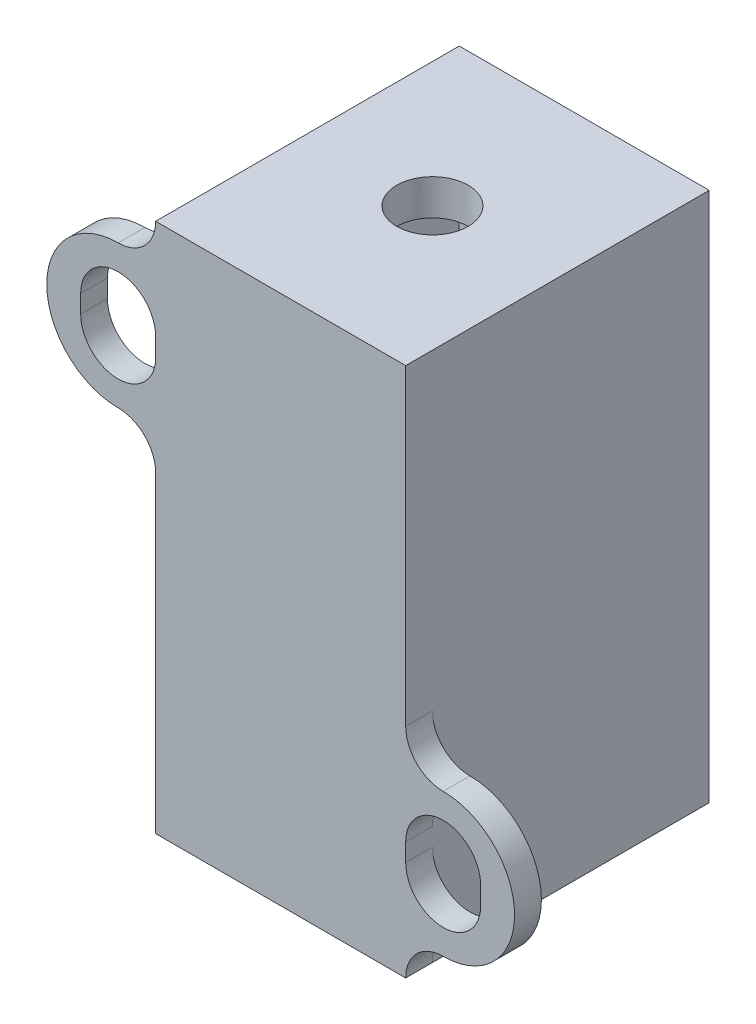
from build123d import *

# Parameters (mm, degrees)
SKETCH1_W           = 14
SKETCH1_H           = 29.7
BOSS_EXTRUDE1_DEPTH = 17
SKETCH2_R           = 2
CUT_EXTRUDE1_DEPTH  = 30.7
SKETCH3_R           = 4
CUT_EXTRUDE2_DEPTH  = 27.7
CUT_EXTRUDE4_START  = -2
SKETCH4_W           = 10
SKETCH4_H           = 13
CUT_EXTRUDE4_DEPTH  = 25.7
BOSS_EXTRUDE2_DEPTH = 1.5


with BuildPart() as part:
    # Sketch1 → Boss-Extrude1 (new body)
    with BuildSketch(Plane.XY):
        with Locations((7, 14.85)):
            Rectangle(SKETCH1_W, SKETCH1_H)
    extrude(amount=BOSS_EXTRUDE1_DEPTH)

    # Sketch2 → Cut-Extrude1 (cut, through all)
    with BuildSketch(Plane(origin=(0, 29.7, 0), x_dir=(1, 0, 0), z_dir=(0, 1, 0))):
        with Locations((7, -8.5)):
            Circle(SKETCH2_R)
    extrude(amount=-CUT_EXTRUDE1_DEPTH, mode=Mode.SUBTRACT)

    # Sketch3 → Cut-Extrude2 (cut)
    with BuildSketch(Plane.XZ):
        with Locations((7, 8.5)):
            Circle(SKETCH3_R)
    extrude(amount=-CUT_EXTRUDE2_DEPTH, mode=Mode.SUBTRACT)

    # Sketch4 → Cut-Extrude4 (cut)
    with BuildSketch(Plane.XZ.offset(CUT_EXTRUDE4_START)):
        with Locations((7, 8.5)):
            Rectangle(SKETCH4_W, SKETCH4_H)
    extrude(amount=-CUT_EXTRUDE4_DEPTH, mode=Mode.SUBTRACT)

    # Sketch5 → Boss-Extrude2 (add)
    with BuildSketch(Plane.XY.offset(17)):
        with BuildLine():
            ThreePointArc((0, 23.1), (-2.1, 21), (-4.2, 23.1))
            Line((-4.2, 23.1), (-4.2, 24.1))
            ThreePointArc((-4.2, 24.1), (-2.1, 26.2), (0, 24.1))
            Line((0, 24.1), (0, 29.7))
            ThreePointArc((0, 29.7), (-0.61507576, 28.21507576), (-2.1, 27.6))
            ThreePointArc((-2.1, 27.6), (-6.1, 23.6), (-2.1, 19.6))
            ThreePointArc((-2.1, 19.6), (-0.61507576, 18.98492424), (0, 17.5))
            Line((0, 17.5), (0, 23.1))
        make_face()
        with BuildLine():
            Line((14, 5.6), (14, 0))
            ThreePointArc((14, 0), (14.61507576, 1.48492424), (16.1, 2.1))
            ThreePointArc((16.1, 2.1), (20.1, 6.1), (16.1, 10.1))
            ThreePointArc((16.1, 10.1), (14.61507576, 10.71507576), (14, 12.2))
            Line((14, 12.2), (14, 6.6))
            ThreePointArc((14, 6.6), (16.1, 8.7), (18.2, 6.6))
            Line((18.2, 6.6), (18.2, 5.6))
            ThreePointArc((18.2, 5.6), (16.1, 3.5), (14, 5.6))
        make_face()
    extrude(amount=-BOSS_EXTRUDE2_DEPTH)


solid = part.part
